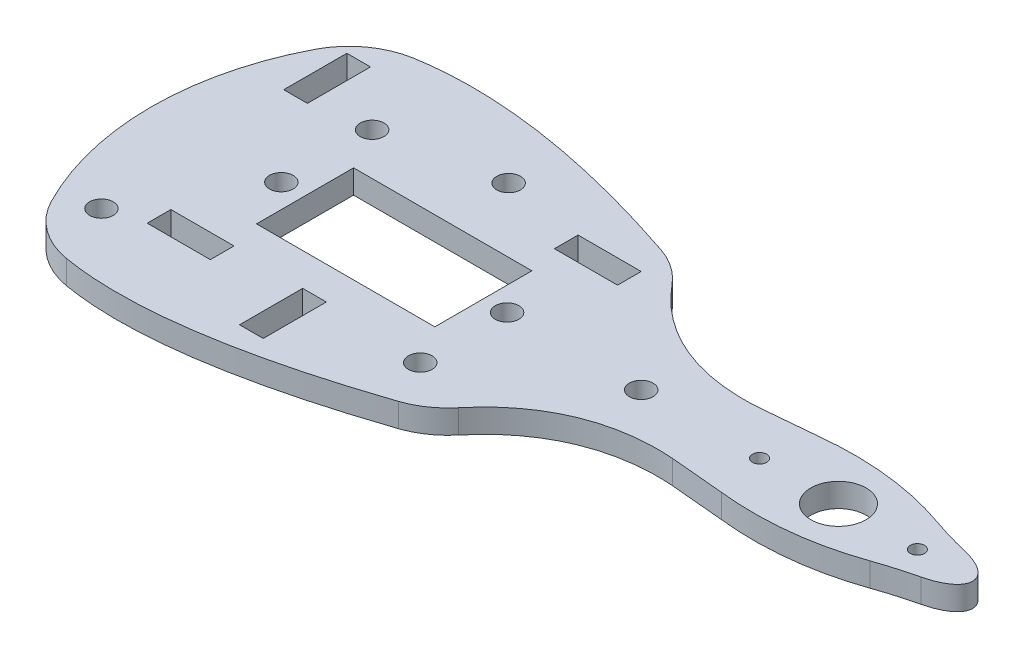
from build123d import *

# Parameters (mm, degrees)
ESBO_O1_R                = 1.5
ESBO_O1_R_2              = 3.5
ESBO_O1_R_3              = 0.9
ESBO_O1_W                = 22.6
ESBO_O1_H                = 12.3
ESBO_O1_W_2              = 3
ESBO_O1_H_2              = 8
ESBO_O1_W_3              = 8
ESBO_O1_H_3              = 3
RESSALTO_EXTRUS_O1_DEPTH = 3


with BuildPart() as part:
    # Esboço1 → Ressalto-extrusão1 (new body)
    with BuildSketch(Plane(origin=(0, 0, 0), x_dir=(1, 0, 0), z_dir=(0, 1, 0))):
        with BuildLine():
            Line((-4.674449837, 5.126823449), (2.15649844, 5.74992269))
            add(Edge.make_bspline(
                [(19.127700004, 3.859391667), (13.692888976, 5.757269931), (8.035822873, 6.387450044), (2.15649844, 5.74992269)],
                knots=[0.35388944, 0.35388944, 0.35388944, 0.35388944, 1, 1, 1, 1], degree=3))
            ThreePointArc((19.127700004, 3.859391667), (21.595587829, 3.06871935), (24.101127023, 2.406974398))
            add(Edge.make_bspline(
                [(24.101129521, -3.20712694), (35.966754752, -0.40007519), (24.101127023, 2.406974398)],
                knots=[5.194112275, 5.194112275, 5.194112275, 7.372258742, 7.372258742, 7.372258742], degree=2, weights=[1, 0.463306864, 1]))
            ThreePointArc((24.101129521, -3.20712694), (21.595589041, -3.868872862), (19.127700004, -4.659546287))
            add(Edge.make_bspline(
                [(19.127700004, -4.659546287), (13.692889505, -6.55742607), (8.035822337, -7.187603127), (2.15649844, -6.55007731)],
                knots=[0.35388944, 0.35388944, 0.35388944, 0.35388944, 1, 1, 1, 1], degree=3))
            Line((2.15649844, -6.55007731), (-4.674449837, -5.926978069))
            add(Edge.make_bspline(
                [(-23.759026807, -13.92609603), (-18.993134449, -8.145749128), (-12.424143506, -5.367564321), (-4.674449837, -5.926978069)],
                knots=[0.101821695, 0.101821695, 0.101821695, 0.101821695, 1, 1, 1, 1], degree=3))
            ThreePointArc((-23.759026807, -13.92609603), (-25.800414194, -15.798822034), (-28.277263571, -17.039621097))
            add(Edge.make_bspline(
                [(-28.277263571, -17.039621097), (-34.579205058, -19.166234), (-47.597806191, -22.747709276), (-59.650258973, -23.294853785), (-64.986052109, -22.387135922)],
                knots=[0.241589655, 0.241589655, 0.241589655, 0.241589655, 0.401358205, 0.561126756, 0.561126756, 0.561126756, 0.561126756], degree=3))
            ThreePointArc((-64.986052109, -22.387135922), (-69.209775007, -20.602207926), (-72.192804257, -17.119774932))
            ThreePointArc((-72.192804257, -17.119774932), (-76.257665323, -0.40007754), (-72.192804468, 16.319619904))
            ThreePointArc((-72.192804468, 16.319619904), (-69.209774999, 19.802053128), (-64.986051746, 21.586981094))
            add(Edge.make_bspline(
                [(-28.2772637, 16.239466453), (-34.57920511, 18.366079177), (-47.597806077, 21.947554059), (-59.650258689, 22.494698656), (-64.986051746, 21.586981094)],
                knots=[0.241589656, 0.241589656, 0.241589656, 0.241589656, 0.401358204, 0.561126752, 0.561126752, 0.561126752, 0.561126752], degree=3))
            ThreePointArc((-28.2772637, 16.239466453), (-25.80041422, 14.998667392), (-23.759026751, 13.125941342))
            add(Edge.make_bspline(
                [(-23.759026751, 13.125941342), (-18.993134399, 7.345594488), (-12.424143468, 4.567409699), (-4.674449837, 5.126823449)],
                knots=[0.101821698, 0.101821698, 0.101821698, 0.101821698, 1, 1, 1, 1], degree=3))
        make_face()
        with Locations((-59.742023738, -0.40007731)):
            Circle(ESBO_O1_R, mode=Mode.SUBTRACT)
        with Locations((-31.142023738, -0.40007731)):
            Circle(ESBO_O1_R, mode=Mode.SUBTRACT)
        with Locations((-45.242023738, 13.89992269)):
            Circle(ESBO_O1_R, mode=Mode.SUBTRACT)
        with Locations((-68.242023738, -14.70007731)):
            Circle(ESBO_O1_R, mode=Mode.SUBTRACT)
        with Locations((-59.742023738, 11.09992269)):
            Circle(ESBO_O1_R, mode=Mode.SUBTRACT)
        with Locations((-31.142023738, -11.40175485)):
            Circle(ESBO_O1_R, mode=Mode.SUBTRACT)
        with Locations((10.857976262, -0.40007731)):
            Circle(ESBO_O1_R_2, mode=Mode.SUBTRACT)
        with Locations((20.857976262, -0.40007731)):
            Circle(ESBO_O1_R_3, mode=Mode.SUBTRACT)
        with Locations((0.857976262, -0.40007731)):
            Circle(ESBO_O1_R_3, mode=Mode.SUBTRACT)
        with Locations((-14.142023738, -0.40007731)):
            Circle(ESBO_O1_R, mode=Mode.SUBTRACT)
        with Locations((-45.442023738, -0.40007731)):
            Rectangle(ESBO_O1_W, ESBO_O1_H, mode=Mode.SUBTRACT)
        with Locations((-45.242023738, -14.70007731)):
            Rectangle(ESBO_O1_W_2, ESBO_O1_H_2, mode=Mode.SUBTRACT)
        with Locations((-68.242023738, 13.89992269)):
            Rectangle(ESBO_O1_W_2, ESBO_O1_H_2, mode=Mode.SUBTRACT)
        with Locations((-31.142023738, 11.099922699)):
            Rectangle(ESBO_O1_W_3, ESBO_O1_H_3, mode=Mode.SUBTRACT)
        with Locations((-59.742023738, -11.90007731)):
            Rectangle(ESBO_O1_W_3, ESBO_O1_H_3, mode=Mode.SUBTRACT)
    extrude(amount=RESSALTO_EXTRUS_O1_DEPTH)


solid = part.part
